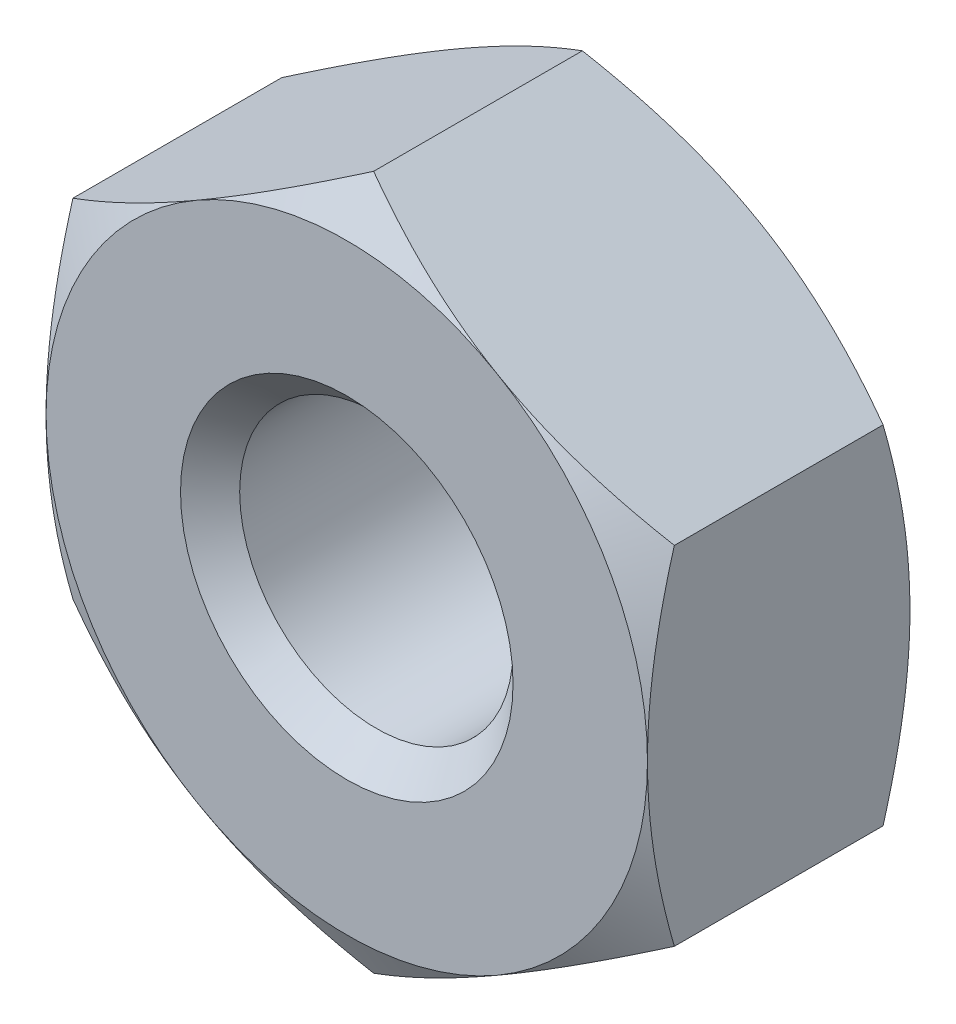
from build123d import *

# Parameters (mm, degrees)
SKETCH2_R           = 1.25
BOSS_EXTRUDE1_DEPTH = 1.2
CHAMFER1_SIZE       = 0.2705


with BuildPart() as part:
    # Sketch2 → Boss-Extrude1 (new body, symmetric)
    with BuildSketch(Plane.XY):
        Polygon((2.75, 1.58771324), (2.75, -1.58771324), (0, -3.175426481), (-2.75, -1.58771324), (-2.75, 1.58771324), (0, 3.175426481), align=None)
        Circle(SKETCH2_R, mode=Mode.SUBTRACT)
    extrude(amount=BOSS_EXTRUDE1_DEPTH, both=True)

    # Sketch4 → Cut-Revolve2 (revolve, cut)
    with BuildSketch(Plane(origin=(0, 0, 0), x_dir=(0, 0, -1), z_dir=(1, 0, 0))):
        Polygon((1.2, 2.75), (1.2, 4.328660734), (0.2885598, 4.328660734), align=None)
    cut_revolve2 = revolve(axis=Axis((0, 0, 2.99453507), (0, 0, -1)), mode=Mode.SUBTRACT)

    # Mirror1: Cut-Revolve2 across plane
    add(cut_revolve2.mirror(Plane.XY), mode=Mode.SUBTRACT)

    # Chamfer1
    chamfer1_edges = [part.edges().sort_by_distance(p)[0] for p in [
        (-1.25, 0, -1.2),
        (-1.25, 0, 1.2),
    ]]
    chamfer(chamfer1_edges, length=CHAMFER1_SIZE)


solid = part.part
